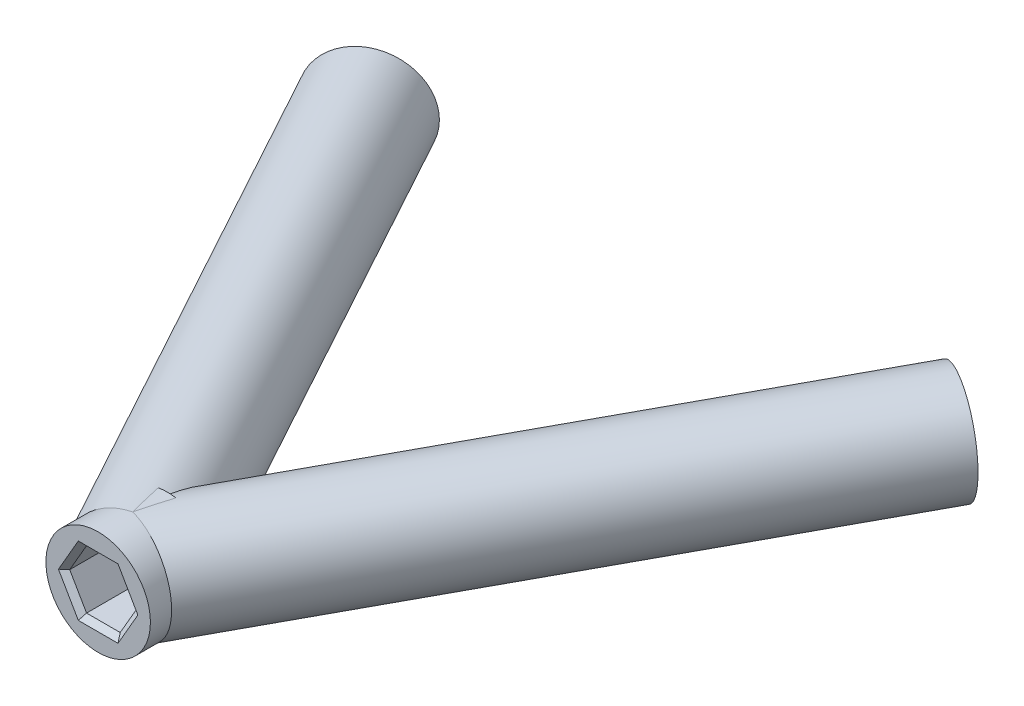
from build123d import *

# Parameters (mm, degrees)
SKETCH1_W           = 5
SKETCH1_H           = 6.6
BOSS_EXTRUDE1_REACH = 64.005
SKETCH21_R          = 5
BOSS_EXTRUDE2_REACH = 78.152
SKETCH22_R          = 5
CUT_EXTRUDE3_DEPTH  = 6.6
CUT_EXTRUDE4_DEPTH  = 6.6
CUT_EXTRUDE5_DEPTH  = 6.6
CHAMFER2_SIZE       = 0.5


with BuildPart() as part:
    # Sketch1 → Revolve-Thin1 (revolve)
    with BuildSketch(Plane(origin=(0, 0, 0), x_dir=(1, 0, 0), z_dir=(0, 1, 0))):
        with Locations((-2.5, 20.8)):
            Rectangle(SKETCH1_W, SKETCH1_H)
    revolve(axis=Axis((0, 0, -17.5), (0, 0, -1)))

    # Sketch21 → Boss-Extrude1 (add, up to next)
    with BuildSketch(Plane(origin=(-35.950232756, 0, -65.780747057), x_dir=(0.877503712, 0, -0.479569845), z_dir=(0.479569845, 0, 0.877503712)), mode=Mode.PRIVATE) as boss_extrude1_sk1:
        with Locations((9.975052777, 0)):
            Circle(SKETCH21_R)
    boss_extrude1_tool1 = extrude(boss_extrude1_sk1.sketch, amount=BOSS_EXTRUDE1_REACH, mode=Mode.PRIVATE) - part.part
    add(boss_extrude1_tool1.solids().sort_by_distance((-27.197087, 0, -70.564482))[0])

    # Sketch22 → Boss-Extrude2 (add, up to next)
    with BuildSketch(Plane(origin=(36.517428466, 0, -67.14845845), x_dir=(0.878494382, 0, 0.477752677), z_dir=(-0.477752677, 0, 0.878494382)), mode=Mode.PRIVATE) as boss_extrude2_sk1:
        with Locations((-9.937255677, 0)):
            Circle(SKETCH22_R)
    boss_extrude2_tool1 = extrude(boss_extrude2_sk1.sketch, amount=BOSS_EXTRUDE2_REACH, mode=Mode.PRIVATE) - part.part
    add(boss_extrude2_tool1.solids().sort_by_distance((27.787605, 0, -71.896009))[0])

    # Sketch29 → Cut-Extrude3 (cut)
    with BuildSketch(Plane(origin=(-35.950232756, 0, -65.780747057), x_dir=(-0.877503712, 0, 0.479569845), z_dir=(-0.479569845, 0, -0.877503712))):
        Polygon((-7.29102946, 1.781802131), (-10.176127029, 3.215333442), (-12.860150346, 1.433531311), (-12.659076094, -1.781802131), (-9.773978525, -3.215333442), (-7.089955208, -1.433531311), align=None)
    extrude(amount=-CUT_EXTRUDE3_DEPTH, mode=Mode.SUBTRACT)

    # Sketch30 → Cut-Extrude4 (cut)
    with BuildSketch(Plane(origin=(36.517428466, 0, -67.14845845), x_dir=(-0.878494382, 0, -0.477752677), z_dir=(0.477752677, 0, -0.878494382))):
        Polygon((9.736181425, -3.215333442), (12.621278993, -1.781802131), (12.822353245, 1.433531311), (10.138329929, 3.215333442), (7.25323236, 1.781802131), (7.052158108, -1.433531311), align=None)
    extrude(amount=-CUT_EXTRUDE4_DEPTH, mode=Mode.SUBTRACT)

    # Sketch18 → Cut-Extrude5 (cut)
    with BuildSketch(Plane.XY.offset(-17.5)):
        Polygon((1.610807251, 2.79), (-1.610807251, 2.79), (-3.221614502, 0), (-1.610807251, -2.79), (1.610807251, -2.79), (3.221614502, 0), align=None)
    extrude(amount=-CUT_EXTRUDE5_DEPTH, mode=Mode.SUBTRACT)

    # Chamfer2
    chamfer2_edges = [part.edges().sort_by_distance(p)[0] for p in [
        (-29.640549045, 0.17413541, -69.229090352),
        (-28.286485432, 2.498567787, -69.969107823),
        (-25.843023308, 2.324432377, -71.304499043),
        (-24.753624798, -0.17413541, -71.899872792),
        (-26.107688412, -2.498567787, -71.159855321),
        (-28.551150535, -2.324432377, -69.824464101),
        (26.696976775, -2.498567787, -72.489126731),
        (25.341384472, -0.17413541, -73.226340155),
        (26.432012874, 2.324432377, -72.633222374),
        (28.87823358, 2.498567787, -71.302891169),
        (30.233825884, 0.17413541, -70.565677745),
        (29.143197481, -2.324432377, -71.158795526),
        (2.416210877, 1.395, -17.5),
        (0, 2.79, -17.5),
        (-2.416210877, 1.395, -17.5),
        (-2.416210877, -1.395, -17.5),
        (0, -2.79, -17.5),
        (2.416210877, -1.395, -17.5),
    ]]
    chamfer(chamfer2_edges, length=CHAMFER2_SIZE)


solid = part.part
